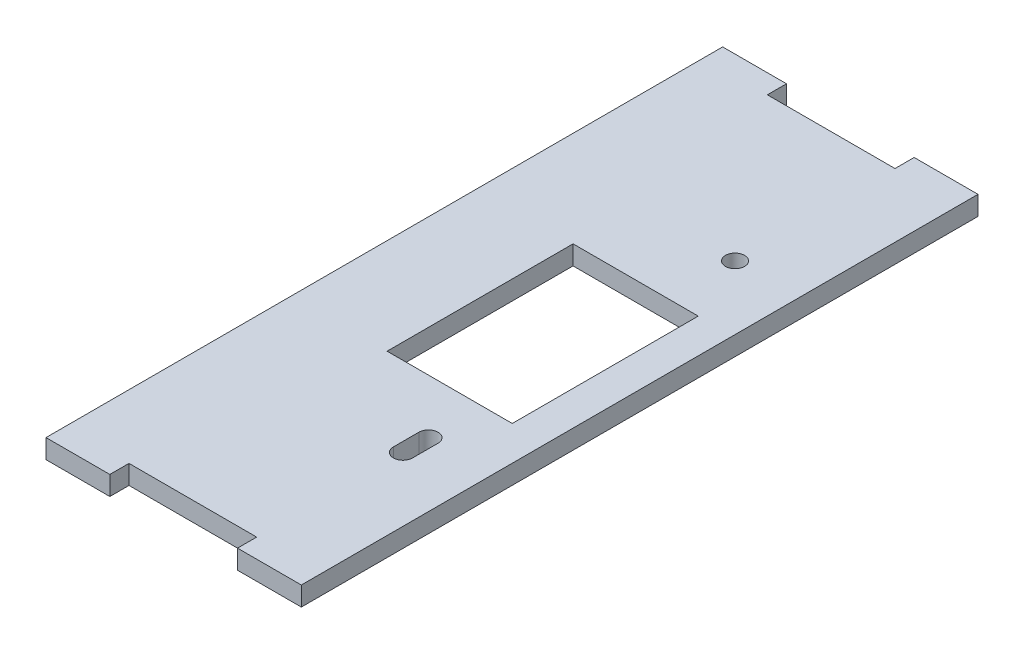
from build123d import *

# Parameters (mm, degrees)
SKETCH1_W           = 120
SKETCH1_H           = 100
BOSS_EXTRUDE1_DEPTH = 3
SKETCH2_W           = 10
SKETCH2_H           = 3
SKETCH2_W_2         = 20
BOSS_EXTRUDE3_DEPTH = 3
SKETCH3_W           = 10
SKETCH3_H           = 3
SKETCH3_W_2         = 20
BOSS_EXTRUDE4_DEPTH = 3
SKETCH5_W           = 80
SKETCH5_H           = 106
CUT_EXTRUDE1_DEPTH  = 3
SKETCH6_R           = 1.5
CUT_EXTRUDE2_DEPTH  = 10
SKETCH7_W           = 19.608717555
SKETCH7_H           = 29.132951796
CUT_EXTRUDE3_DEPTH  = 10


with BuildPart() as part:
    # Sketch1 → Boss-Extrude1 (new body)
    with BuildSketch(Plane(origin=(0, 0, 0), x_dir=(1, 0, 0), z_dir=(0, 1, 0))):
        with Locations((60, 50)):
            Rectangle(SKETCH1_W, SKETCH1_H)
    extrude(amount=BOSS_EXTRUDE1_DEPTH)

    # Sketch2 → Boss-Extrude3 (add)
    with BuildSketch(Plane(origin=(0, 3, 0), x_dir=(1, 0, 0), z_dir=(0, 1, 0))):
        with Locations((5, -1.5)):
            Rectangle(SKETCH2_W, SKETCH2_H)
        with Locations((40, -1.5)):
            Rectangle(SKETCH2_W_2, SKETCH2_H)
        with Locations((80, -1.5)):
            Rectangle(SKETCH2_W_2, SKETCH2_H)
        with Locations((115, -1.5)):
            Rectangle(SKETCH2_W, SKETCH2_H)
    extrude(amount=-BOSS_EXTRUDE3_DEPTH)

    # Sketch3 → Boss-Extrude4 (add)
    with BuildSketch(Plane.XZ):
        with Locations((5, -101.5)):
            Rectangle(SKETCH3_W, SKETCH3_H)
        with Locations((40, -101.5)):
            Rectangle(SKETCH3_W_2, SKETCH3_H)
        with Locations((80, -101.5)):
            Rectangle(SKETCH3_W_2, SKETCH3_H)
        with Locations((115, -101.5)):
            Rectangle(SKETCH3_W, SKETCH3_H)
    extrude(amount=-BOSS_EXTRUDE4_DEPTH)

    # Sketch5 → Cut-Extrude1 (cut)
    with BuildSketch(Plane.XZ):
        with Locations((80, -50)):
            Rectangle(SKETCH5_W, SKETCH5_H)
    extrude(amount=-CUT_EXTRUDE1_DEPTH, mode=Mode.SUBTRACT)

    # Sketch6 → Cut-Extrude2 (cut)
    with BuildSketch(Plane.XZ):
        with Locations((30, -74.938410105)):
            Circle(SKETCH6_R)
        with BuildLine():
            Line((31.476820396, -26.938410105), (31.476820396, -22.938410105))
            ThreePointArc((31.476820396, -22.938410105), (29.976820396, -21.438410105), (28.476820396, -22.938410105))
            Line((28.476820396, -22.938410105), (28.476820396, -26.938410105))
            ThreePointArc((28.476820396, -26.938410105), (29.976820396, -28.438410105), (31.476820396, -26.938410105))
        make_face()
    extrude(amount=-CUT_EXTRUDE2_DEPTH, mode=Mode.SUBTRACT)

    # Sketch7 → Cut-Extrude3 (cut)
    with BuildSketch(Plane.XZ):
        with Locations((24.804358778, -50)):
            Rectangle(SKETCH7_W, SKETCH7_H)
    extrude(amount=-CUT_EXTRUDE3_DEPTH, mode=Mode.SUBTRACT)


solid = part.part
